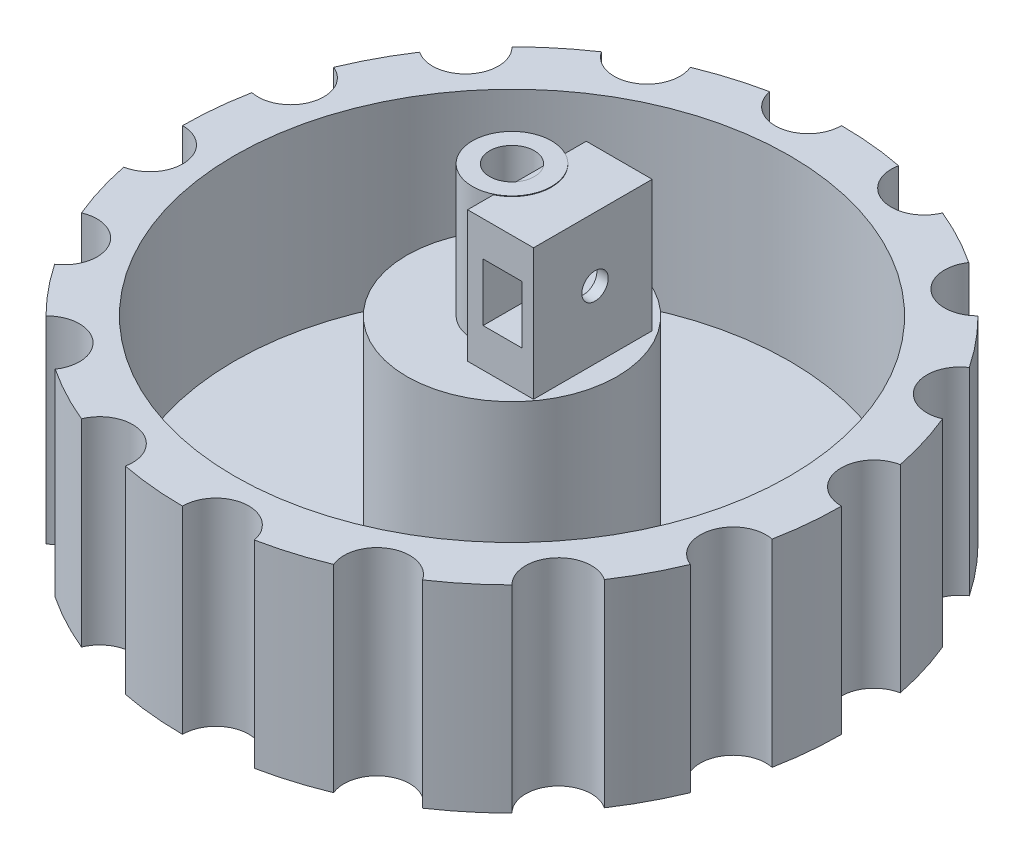
from build123d import *

# Parameters (mm, degrees)
SKETCH1_R               = 6
BOSS_EXTRUDE1_DEPTH     = 20
SKETCH2_R               = 3.4
CUT_EXTRUDE1_DEPTH      = 13.55
SKETCH5_W               = 1.550685087
SKETCH5_H               = 7.184215806
BOSS_EXTRUDE2_DEPTH     = 13.55
SKETCH7_W               = 18.003976239
SKETCH7_H               = 19.909960041
BOSS_EXTRUDE3_DEPTH     = 10
SKETCH6_R               = 2
CUT_EXTRUDE2_DEPTH      = 1
CUT_EXTRUDE2_DEPTH_BACK = 13.55
CUT_EXTRUDE3_DEPTH      = 10
CUT_EXTRUDE3_DEPTH_BACK = 10
SKETCH10_R              = 50
BOSS_EXTRUDE4_DEPTH     = 30
SKETCH11_R              = 5
CUT_EXTRUDE4_DEPTH      = 30
SKETCH12_R              = 42.124366513
SKETCH12_R_2            = 15.95790089
CUT_EXTRUDE5_DEPTH      = 27


with BuildPart() as part:
    # Sketch1 → Boss-Extrude1 (new body)
    with BuildSketch(Plane(origin=(0, 0, 0), x_dir=(1, 0, 0), z_dir=(0, 1, 0))):
        Circle(SKETCH1_R)
    extrude(amount=BOSS_EXTRUDE1_DEPTH)

    # Sketch2 → Cut-Extrude1 (cut)
    with BuildSketch(Plane(origin=(0, 20, 0), x_dir=(1, 0, 0), z_dir=(0, 1, 0))):
        Circle(SKETCH2_R)
    extrude(amount=-CUT_EXTRUDE1_DEPTH, mode=Mode.SUBTRACT)

    # Sketch5 → Boss-Extrude2 (add)
    with BuildSketch(Plane(origin=(0, 18.26, 0), x_dir=(1, 0, 0), z_dir=(0, 1, 0))):
        with Locations((3.375342544, 0.020519704)):
            Rectangle(SKETCH5_W, SKETCH5_H)
    extrude(amount=-BOSS_EXTRUDE2_DEPTH)

    # Sketch7 → Boss-Extrude3 (add)
    with BuildSketch(Plane.ZY.offset(-2.6)):
        with Locations((0.33027221, 9.954980021)):
            Rectangle(SKETCH7_W, SKETCH7_H)
    extrude(amount=-BOSS_EXTRUDE3_DEPTH)

    # Sketch6 → Cut-Extrude2 (cut, two sides)
    with BuildSketch(Plane.ZY.offset(-2.6)) as cut_extrude2_sk:
        with Locations((0, 10.236925537)):
            Circle(SKETCH6_R)
    extrude(amount=CUT_EXTRUDE2_DEPTH, mode=Mode.SUBTRACT)
    extrude(cut_extrude2_sk.sketch, amount=-CUT_EXTRUDE2_DEPTH_BACK, mode=Mode.SUBTRACT)

    # Sketch9 → Cut-Extrude3 (cut, two sides)
    with BuildSketch(Plane.XY) as cut_extrude3_sk:
        Polygon((10.876516382, 10.236925537), (10.876516382, 5.861925537), (4.943430227, 5.861925537), (4.943430227, 10.236925537), (4.943430227, 14.614332445), (10.876516382, 14.614332445), align=None)
    extrude(amount=CUT_EXTRUDE3_DEPTH, mode=Mode.SUBTRACT)
    extrude(cut_extrude3_sk.sketch, amount=-CUT_EXTRUDE3_DEPTH_BACK, mode=Mode.SUBTRACT)

    # Sketch10 → Boss-Extrude4 (add)
    with BuildSketch(Plane.XZ):
        Circle(SKETCH10_R)
    extrude(amount=BOSS_EXTRUDE4_DEPTH)

    # Sketch11 → Cut-Extrude4 (cut)
    with BuildSketch(Plane(origin=(0, 0, 0), x_dir=(1, 0, 0), z_dir=(0, 1, 0))):
        with Locations((5, -49.946157791)):
            Circle(SKETCH11_R)
        with Locations((-14.494169434, -48.057650072)):
            Circle(SKETCH11_R)
        with Locations((-31.781732962, -38.852800774)):
            Circle(SKETCH11_R)
        with Locations((-44.230815749, -23.732964759)):
            Circle(SKETCH11_R)
        with Locations((-49.946157791, -5)):
            Circle(SKETCH11_R)
        with Locations((-48.057650072, 14.494169434)):
            Circle(SKETCH11_R)
        with Locations((-38.852800774, 31.781732962)):
            Circle(SKETCH11_R)
        with Locations((-23.732964759, 44.230815749)):
            Circle(SKETCH11_R)
        with Locations((-5, 49.946157791)):
            Circle(SKETCH11_R)
        with Locations((14.494169434, 48.057650072)):
            Circle(SKETCH11_R)
        with Locations((31.781732962, 38.852800774)):
            Circle(SKETCH11_R)
        with Locations((44.230815749, 23.732964759)):
            Circle(SKETCH11_R)
        with Locations((49.946157791, 5)):
            Circle(SKETCH11_R)
        with Locations((48.057650072, -14.494169434)):
            Circle(SKETCH11_R)
        with Locations((38.852800774, -31.781732962)):
            Circle(SKETCH11_R)
        with Locations((23.732964759, -44.230815749)):
            Circle(SKETCH11_R)
    extrude(amount=-CUT_EXTRUDE4_DEPTH, mode=Mode.SUBTRACT)

    # Sketch12 → Cut-Extrude5 (cut)
    with BuildSketch(Plane(origin=(0, 0, 0), x_dir=(1, 0, 0), z_dir=(0, 1, 0))):
        Circle(SKETCH12_R)
        Circle(SKETCH12_R_2, mode=Mode.SUBTRACT)
    extrude(amount=-CUT_EXTRUDE5_DEPTH, mode=Mode.SUBTRACT)


solid = part.part
